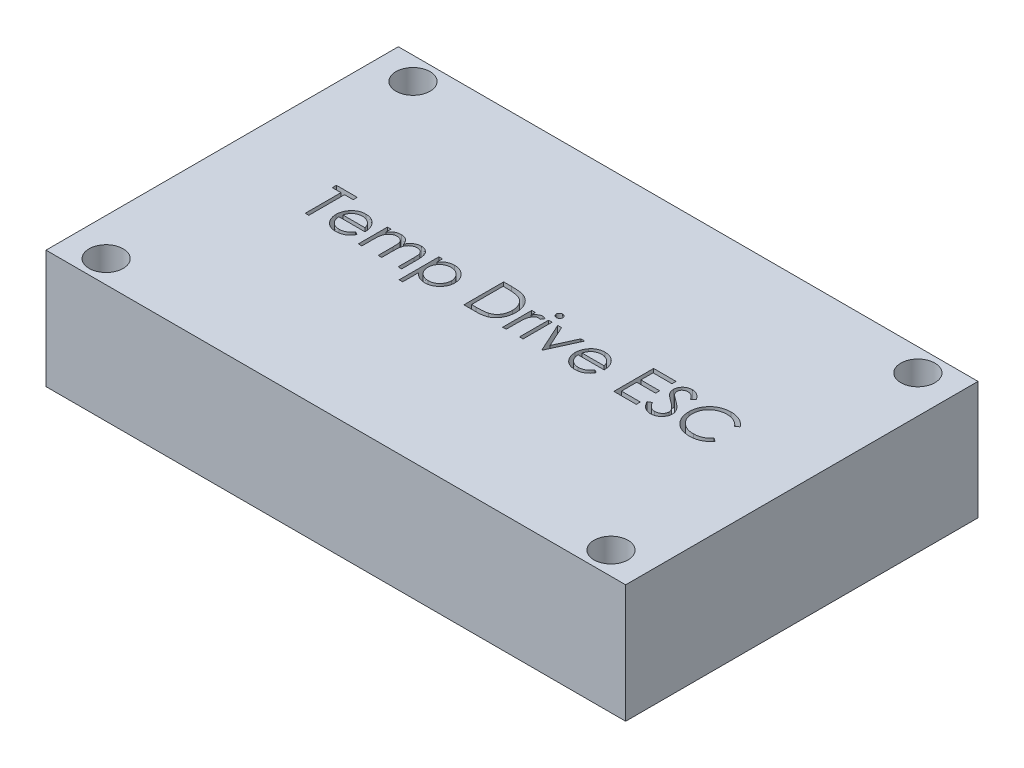
from build123d import *

# Parameters (mm, degrees)
SKETCH1_W           = 51
SKETCH1_H           = 31
SKETCH1_R           = 1.5
BOSS_EXTRUDE1_DEPTH = 10.4
SKETCH2_W           = 0.314102564
SKETCH2_H           = 2.557692308
CUT_EXTRUDE1_DEPTH  = 1.4


with BuildPart() as part:
    # Sketch1 → Boss-Extrude1 (new body)
    with BuildSketch(Plane(origin=(0, 0, 0), x_dir=(1, 0, 0), z_dir=(0, 1, 0))):
        Rectangle(SKETCH1_W, SKETCH1_H)
        with Locations((-22.209677419, 13.5)):
            Circle(SKETCH1_R, mode=Mode.SUBTRACT)
        with Locations((22.209677419, 13.5)):
            Circle(SKETCH1_R, mode=Mode.SUBTRACT)
        with Locations((22.209677419, -13.5)):
            Circle(SKETCH1_R, mode=Mode.SUBTRACT)
        with Locations((-22.209677419, -13.5)):
            Circle(SKETCH1_R, mode=Mode.SUBTRACT)
    extrude(amount=BOSS_EXTRUDE1_DEPTH)

    # Sketch2 → Cut-Extrude1 (cut)
    with BuildSketch(Plane(origin=(0, 10.4, 0), x_dir=(1, 0, 0), z_dir=(0, 1, 0))):
        Polygon((-17.667113502, 1.856715019), (-17.667113502, 2.215689378), (-15.827369912, 2.215689378), (-15.827369912, 1.856715019), (-16.590190425, 1.856715019), (-16.590190425, -1.284310622), (-16.904292989, -1.284310622), (-16.904292989, 1.856715019), align=None)
        with BuildLine():
            Line((-13.279493309, -0.476618314), (-13.000446835, -0.62315277))
            add(Edge.make_bspline(
                [(-13.000446835, -0.62315277), (-13.02268343, -0.662596101), (-13.065947039, -0.739337204), (-13.140347787, -0.844769064), (-13.218339859, -0.93961678), (-13.303443827, -1.021346434), (-13.393113506, -1.092597819), (-13.487846161, -1.154935644), (-13.588134979, -1.208054164), (-13.693984703, -1.252806692), (-13.806284255, -1.287216186), (-13.925305771, -1.311520407), (-14.051277266, -1.326543676), (-14.137623446, -1.328288817), (-14.181837059, -1.329182417)],
                knots=[0, 0, 0, 0, 0.000135759, 0.000264133, 0.000386579, 0.000503597, 0.000617365, 0.000729763, 0.000843304, 0.000957371, 0.001074023, 0.001195027, 0.001321389, 0.001453992, 0.001453992, 0.001453992, 0.001453992], degree=3))
            add(Edge.make_bspline(
                [(-14.181837059, -1.329182417), (-14.230979037, -1.328035242), (-14.326840799, -1.325797435), (-14.466380546, -1.306504971), (-14.597759964, -1.275032612), (-14.720971667, -1.23106707), (-14.83571392, -1.173639746), (-14.942214775, -1.103680264), (-15.041034301, -1.02154801), (-15.12905851, -0.926531566), (-15.208302393, -0.824849609), (-15.278228213, -0.718893724), (-15.336685644, -0.6089305), (-15.384238254, -0.495659976), (-15.422643119, -0.379796082), (-15.449409823, -0.260284615), (-15.464839571, -0.137449031), (-15.467204016, -0.054351695), (-15.468395553, -0.012475686)],
                knots=[0, 0, 0, 0, 0.000147371, 0.000287478, 0.000421649, 0.000552053, 0.000679042, 0.000805636, 0.000933558, 0.00106351, 0.001193382, 0.001319977, 0.001443869, 0.001566405, 0.001688128, 0.001809576, 0.001933238, 0.002058864, 0.002058864, 0.002058864, 0.002058864], degree=3))
            add(Edge.make_bspline(
                [(-15.468395553, -0.012475686), (-15.467336412, 0.026819144), (-15.465237333, 0.104696309), (-15.452006546, 0.219961853), (-15.428558253, 0.331990306), (-15.396381929, 0.440874754), (-15.354830683, 0.546432888), (-15.303998464, 0.648728951), (-15.243806086, 0.747654091), (-15.197333412, 0.810057225), (-15.173924399, 0.84149066)],
                knots=[0, 0, 0, 0, 0.000117891, 0.000233644, 0.000347498, 0.000460856, 0.000573868, 0.000687374, 0.000803169, 0.000920699, 0.000920699, 0.000920699, 0.000920699], degree=3))
            add(Edge.make_bspline(
                [(-15.173924399, 0.84149066), (-15.142216716, 0.87935953), (-15.07980577, 0.95389768), (-14.974249414, 1.051836006), (-14.859949218, 1.133879781), (-14.738337592, 1.201886918), (-14.608001118, 1.253560565), (-14.470691827, 1.292068147), (-14.324846241, 1.313646158), (-14.22514102, 1.316693991), (-14.17412472, 1.31825348)],
                knots=[0, 0, 0, 0, 0.000148071, 0.000291452, 0.00043058, 0.000569298, 0.000708346, 0.00085021, 0.000996268, 0.001149307, 0.001149307, 0.001149307, 0.001149307], degree=3))
            add(Edge.make_bspline(
                [(-14.17412472, 1.31825348), (-14.121677114, 1.316899432), (-14.018786868, 1.314243096), (-13.868754747, 1.289616763), (-13.726794031, 1.250564208), (-13.592961527, 1.195410418), (-13.467243666, 1.124250866), (-13.350457616, 1.036109025), (-13.240606104, 0.933690937), (-13.176697525, 0.854927728), (-13.144176803, 0.814848032)],
                knots=[0, 0, 0, 0, 0.000157241, 0.00030847, 0.000454763, 0.000598116, 0.000741606, 0.000886879, 0.001036172, 0.001190853, 0.001190853, 0.001190853, 0.001190853], degree=3))
            add(Edge.make_bspline(
                [(-13.144176803, 0.814848032), (-13.122049865, 0.78464445), (-13.077943272, 0.724438332), (-13.022696172, 0.626267175), (-12.974738777, 0.52355658), (-12.936405816, 0.414646283), (-12.905366314, 0.300826703), (-12.882909496, 0.181284158), (-12.869739877, 0.056054247), (-12.86715118, -0.029272309), (-12.86583145, -0.072772161)],
                knots=[0, 0, 0, 0, 0.000112234, 0.000223721, 0.000337279, 0.000451932, 0.000569628, 0.000690912, 0.000816421, 0.00094695, 0.00094695, 0.00094695, 0.00094695], degree=3))
            Line((-12.86583145, -0.072772161), (-15.154292989, -0.072772161))
            add(Edge.make_bspline(
                [(-15.154292989, -0.072772161), (-15.152753382, -0.106472625), (-15.149725808, -0.172743229), (-15.135610665, -0.269714012), (-15.113361892, -0.362087354), (-15.082092829, -0.449170396), (-15.044225984, -0.532100523), (-14.997840267, -0.61026256), (-14.942500713, -0.68330049), (-14.880775014, -0.751867628), (-14.812067918, -0.812928389), (-14.739785171, -0.867580165), (-14.662891606, -0.913385762), (-14.581993522, -0.950565652), (-14.497221737, -0.979671968), (-14.408549542, -0.999539789), (-14.316151426, -1.012846895), (-14.253165692, -1.014326561), (-14.22109988, -1.015079853)],
                knots=[0, 0, 0, 0, 0.000101159, 0.000198924, 0.000293472, 0.000385722, 0.000476069, 0.000566611, 0.000657757, 0.000750573, 0.000842919, 0.000933083, 0.001022062, 0.001110842, 0.001199752, 0.001290403, 0.001383113, 0.001479259, 0.001479259, 0.001479259, 0.001479259], degree=3))
            add(Edge.make_bspline(
                [(-14.22109988, -1.015079853), (-14.189748732, -1.014471796), (-14.127542041, -1.013265295), (-14.034901184, -1.001533384), (-13.943761657, -0.982563109), (-13.854500673, -0.956673119), (-13.768929827, -0.925096266), (-13.689684277, -0.886993409), (-13.616804062, -0.844843662), (-13.548687095, -0.796633987), (-13.482616102, -0.7376258), (-13.417073615, -0.663990079), (-13.346796962, -0.576902551), (-13.302807369, -0.511356885), (-13.279493309, -0.476618314)],
                knots=[0, 0, 0, 0, 9.4016e-05, 0.000186545, 0.000279636, 0.000373054, 0.000465125, 0.000552934, 0.000636508, 0.000717442, 0.000802858, 0.000901616, 0.001012865, 0.001138311, 0.001138311, 0.001138311, 0.001138311], degree=3))
        make_face()
        with BuildLine():
            add(Edge.make_bspline(
                [(-13.179934015, 0.241330403), (-13.191430639, 0.282993277), (-13.213557941, 0.363180898), (-13.259794305, 0.474221788), (-13.311865846, 0.572909689), (-13.373487577, 0.658489322), (-13.443306303, 0.734492835), (-13.523951485, 0.80091142), (-13.614387379, 0.860328872), (-13.71414652, 0.910481371), (-13.819788305, 0.95317123), (-13.930394497, 0.981796345), (-14.043252284, 1.001405888), (-14.119586571, 1.003231996), (-14.157998918, 1.004150916)],
                knots=[0, 0, 0, 0, 0.000129543, 0.000249328, 0.000360065, 0.000463575, 0.000564789, 0.000668832, 0.000776175, 0.000888744, 0.001003316, 0.001117263, 0.001230914, 0.001346035, 0.001346035, 0.001346035, 0.001346035], degree=3))
            add(Edge.make_bspline(
                [(-14.157998918, 1.004150916), (-14.189348357, 1.003539245), (-14.251319606, 1.002330099), (-14.342620674, 0.990859969), (-14.430300373, 0.971900125), (-14.515005661, 0.945935168), (-14.595626529, 0.911326565), (-14.673821297, 0.870743339), (-14.747601693, 0.821201755), (-14.793742989, 0.7834429), (-14.817053406, 0.764367262)],
                knots=[0, 0, 0, 0, 9.4016e-05, 0.000185849, 0.000275511, 0.000362884, 0.000451173, 0.00053836, 0.000626838, 0.000717174, 0.000717174, 0.000717174, 0.000717174], degree=3))
            add(Edge.make_bspline(
                [(-14.817053406, 0.764367262), (-14.833746687, 0.749272947), (-14.867529822, 0.718725731), (-14.912670343, 0.666096524), (-14.955890816, 0.609344962), (-14.995224469, 0.546299837), (-15.031302055, 0.477679058), (-15.065062032, 0.404061423), (-15.095448444, 0.324888293), (-15.112544554, 0.269715854), (-15.121340265, 0.241330403)],
                knots=[0, 0, 0, 0, 6.7454e-05, 0.00013651, 0.000207604, 0.000281328, 0.000359112, 0.000440057, 0.000524171, 0.000613305, 0.000613305, 0.000613305, 0.000613305], degree=3))
            Line((-15.121340265, 0.241330403), (-13.179934015, 0.241330403))
        make_face(mode=Mode.SUBTRACT)
        with BuildLine():
            Line((-12.237626322, 1.273381686), (-11.923523758, 1.273381686))
            Line((-11.923523758, 1.273381686), (-11.923523758, 0.828870468))
            add(Edge.make_bspline(
                [(-11.923523758, 0.828870468), (-11.895239808, 0.867758069), (-11.841045049, 0.942270442), (-11.752179396, 1.040460727), (-11.663403284, 1.123788881), (-11.599469902, 1.167531753), (-11.56875613, 1.188545948)],
                knots=[0, 0, 0, 0, 0.000144152, 0.000276209, 0.000396804, 0.000508302, 0.000508302, 0.000508302, 0.000508302], degree=3))
            add(Edge.make_bspline(
                [(-11.56875613, 1.188545948), (-11.526891468, 1.208551314), (-11.443893568, 1.248212527), (-11.312474343, 1.288446086), (-11.177999674, 1.313171187), (-11.08719146, 1.316552561), (-11.04151254, 1.31825348)],
                knots=[0, 0, 0, 0, 0.000139031, 0.000275633, 0.000410962, 0.000547939, 0.000547939, 0.000547939, 0.000547939], degree=3))
            add(Edge.make_bspline(
                [(-11.04151254, 1.31825348), (-11.010619544, 1.31720819), (-10.949483965, 1.315139615), (-10.858899874, 1.30167958), (-10.771041263, 1.278413407), (-10.686427233, 1.246006083), (-10.606706554, 1.206759396), (-10.533617356, 1.160709688), (-10.467993148, 1.109012613), (-10.409867097, 1.04933368), (-10.357598071, 0.979997081), (-10.309519225, 0.899132833), (-10.265094012, 0.804925172), (-10.240472704, 0.736558631), (-10.227510136, 0.700565179)],
                knots=[0, 0, 0, 0, 9.2678e-05, 0.000183405, 0.000274048, 0.000364807, 0.000454797, 0.00054019, 0.000623517, 0.000704829, 0.000789387, 0.000883415, 0.000986597, 0.001101318, 0.001101318, 0.001101318, 0.001101318], degree=3))
            add(Edge.make_bspline(
                [(-10.227510136, 0.700565179), (-10.213798885, 0.725289598), (-10.186817068, 0.773943783), (-10.141511431, 0.842802046), (-10.094043634, 0.907208837), (-10.044009141, 0.967215262), (-9.991584554, 1.022524992), (-9.936523154, 1.073320894), (-9.879138373, 1.119821108), (-9.799346133, 1.174144267), (-9.695533525, 1.231845448), (-9.564645411, 1.281873892), (-9.428495239, 1.312790021), (-9.336077541, 1.316420294), (-9.289409175, 1.31825348)],
                knots=[0, 0, 0, 0, 8.4789e-05, 0.000166854, 0.000247064, 0.000324714, 0.000401089, 0.000475513, 0.000549314, 0.000622436, 0.0007649, 0.000904487, 0.001041601, 0.001181469, 0.001181469, 0.001181469, 0.001181469], degree=3))
            add(Edge.make_bspline(
                [(-9.289409175, 1.31825348), (-9.246527712, 1.31663626), (-9.162604526, 1.313471201), (-9.04042726, 1.288617728), (-8.926485455, 1.245940081), (-8.821008379, 1.187706444), (-8.725848565, 1.114527261), (-8.643132256, 1.027458423), (-8.573361893, 0.9271158), (-8.527783253, 0.832723812), (-8.496867989, 0.749388479), (-8.477806754, 0.678382188), (-8.460967059, 0.600230635), (-8.446985814, 0.514840373), (-8.436767262, 0.421909765), (-8.429196546, 0.321590889), (-8.424072473, 0.213805777), (-8.423710401, 0.139440277), (-8.423523758, 0.101106045)],
                knots=[0, 0, 0, 0, 0.000128581, 0.000251645, 0.00037211, 0.000492305, 0.000611786, 0.000730807, 0.000851198, 0.000976936, 0.001044145, 0.001117629, 0.001197252, 0.00128393, 0.001377074, 0.001477631, 0.001585715, 0.001700707, 0.001700707, 0.001700707, 0.001700707], degree=3))
            Line((-8.423523758, 0.101106045), (-8.423523758, -1.284310622))
            Line((-8.423523758, -1.284310622), (-8.737626322, -1.284310622))
            Line((-8.737626322, -1.284310622), (-8.737626322, 0.102508288))
            add(Edge.make_bspline(
                [(-8.737626322, 0.102508288), (-8.737704205, 0.135228862), (-8.737853884, 0.198112829), (-8.740547516, 0.28836528), (-8.74562283, 0.370633637), (-8.751557469, 0.444805725), (-8.759801278, 0.511054514), (-8.77044721, 0.569246933), (-8.78172489, 0.619840744), (-8.800460881, 0.675926792), (-8.830408773, 0.737797002), (-8.876026253, 0.804520578), (-8.933496359, 0.862601378), (-8.999856515, 0.913019695), (-9.07540496, 0.954013336), (-9.158669683, 0.983289346), (-9.249133735, 1.001412224), (-9.311756523, 1.00321824), (-9.344096675, 1.004150916)],
                knots=[0, 0, 0, 0, 9.816e-05, 0.000188648, 0.000270826, 0.000345412, 0.000411852, 0.000470988, 0.000522857, 0.0005672, 0.000648106, 0.000728233, 0.000808554, 0.000892128, 0.000977461, 0.001065278, 0.001156029, 0.001252946, 0.001252946, 0.001252946, 0.001252946], degree=3))
            add(Edge.make_bspline(
                [(-9.344096675, 1.004150916), (-9.383766629, 1.002734759), (-9.46216954, 0.999935894), (-9.576615027, 0.971362021), (-9.686586043, 0.92828177), (-9.788801176, 0.865849313), (-9.882828967, 0.791040949), (-9.963728544, 0.702091353), (-10.03056073, 0.601461426), (-10.075814706, 0.508314724), (-10.104404007, 0.42464528), (-10.123280923, 0.351547908), (-10.137964315, 0.26846634), (-10.151734844, 0.175958849), (-10.160722572, 0.073388669), (-10.168890944, -0.038769732), (-10.172711807, -0.160853691), (-10.173246266, -0.24548038), (-10.173523758, -0.289418795)],
                knots=[0, 0, 0, 0, 0.000118788, 0.00023477, 0.000351815, 0.000471937, 0.000592603, 0.000711217, 0.000831002, 0.000953929, 0.001020668, 0.001096002, 0.00118016, 0.001273662, 0.001376495, 0.001488939, 0.001611007, 0.001742825, 0.001742825, 0.001742825, 0.001742825], degree=3))
            Line((-10.173523758, -0.289418795), (-10.173523758, -1.284310622))
            Line((-10.173523758, -1.284310622), (-10.487626322, -1.284310622))
            Line((-10.487626322, -1.284310622), (-10.487626322, 0.016270307))
            add(Edge.make_bspline(
                [(-10.487626322, 0.016270307), (-10.487705753, 0.052963626), (-10.48785857, 0.123557883), (-10.490534888, 0.224791559), (-10.495621509, 0.316872639), (-10.501502058, 0.399694103), (-10.509962236, 0.473105431), (-10.519571998, 0.537500189), (-10.530920609, 0.59271694), (-10.549710494, 0.653280325), (-10.578424962, 0.720001248), (-10.624613224, 0.791142269), (-10.682220804, 0.853410367), (-10.74979168, 0.906569115), (-10.825797362, 0.950510597), (-10.909780763, 0.982170348), (-11.000985676, 1.000594638), (-11.063863382, 1.002943135), (-11.09620004, 1.004150916)],
                knots=[0, 0, 0, 0, 0.000110078, 0.00021178, 0.000303758, 0.00038673, 0.000460827, 0.00052538, 0.000582037, 0.000629718, 0.00071543, 0.000799052, 0.000882908, 0.000968755, 0.001056067, 0.001145266, 0.001236843, 0.001333803, 0.001333803, 0.001333803, 0.001333803], degree=3))
            add(Edge.make_bspline(
                [(-11.09620004, 1.004150916), (-11.134216252, 1.002620456), (-11.209981211, 0.999570304), (-11.321283181, 0.97211603), (-11.428768864, 0.929111955), (-11.530723563, 0.869452136), (-11.624397711, 0.795553058), (-11.706405979, 0.708638162), (-11.775348504, 0.609789128), (-11.821080319, 0.517624612), (-11.850578793, 0.436051337), (-11.870174128, 0.366700389), (-11.887013754, 0.289700141), (-11.899527775, 0.20481303), (-11.911608191, 0.112591936), (-11.9174385, 0.012577446), (-11.923110062, -0.095144642), (-11.923382477, -0.169517187), (-11.923523758, -0.208088667)],
                knots=[0, 0, 0, 0, 0.000113893, 0.000226985, 0.000341817, 0.000460265, 0.000580056, 0.000698595, 0.000817435, 0.000940348, 0.001005999, 0.001077458, 0.001156396, 0.001242271, 0.001334801, 0.001435306, 0.00154269, 0.001658383, 0.001658383, 0.001658383, 0.001658383], degree=3))
            Line((-11.923523758, -0.208088667), (-11.923523758, -1.284310622))
            Line((-11.923523758, -1.284310622), (-12.237626322, -1.284310622))
            Line((-12.237626322, -1.284310622), (-12.237626322, 1.273381686))
        make_face()
        with BuildLine():
            Line((-7.70557504, 1.273381686), (-7.391472476, 1.273381686))
            Line((-7.391472476, 1.273381686), (-7.391472476, 0.800124474))
            add(Edge.make_bspline(
                [(-7.391472476, 0.800124474), (-7.358114992, 0.843062208), (-7.293291397, 0.926503101), (-7.181566492, 1.034493229), (-7.063639684, 1.125568533), (-6.936476271, 1.196951066), (-6.802052581, 1.250771878), (-6.660920264, 1.290551328), (-6.511881499, 1.313992802), (-6.409985046, 1.316814464), (-6.35801895, 1.31825348)],
                knots=[0, 0, 0, 0, 0.00016294, 0.00031664, 0.000464722, 0.000608822, 0.000752559, 0.000898176, 0.001047911, 0.001203751, 0.001203751, 0.001203751, 0.001203751], degree=3))
            add(Edge.make_bspline(
                [(-6.35801895, 1.31825348), (-6.312627347, 1.316940302), (-6.222908459, 1.314344734), (-6.09084523, 1.29677168), (-5.963669846, 1.266653987), (-5.842101792, 1.223253072), (-5.724838727, 1.169597602), (-5.613616627, 1.101880567), (-5.506703072, 1.023474376), (-5.406786883, 0.933242225), (-5.314465515, 0.835613959), (-5.234619334, 0.730591654), (-5.16574743, 0.621629068), (-5.110077133, 0.507036976), (-5.066468786, 0.387717746), (-5.035454108, 0.263189305), (-5.016996465, 0.133913365), (-5.014520013, 0.046010644), (-5.013267348, 0.00154675)],
                knots=[0, 0, 0, 0, 0.000136164, 0.000269135, 0.000398888, 0.000527501, 0.000655799, 0.000785059, 0.000917435, 0.001052984, 0.001188402, 0.001319939, 0.001448139, 0.001574506, 0.001701376, 0.001828571, 0.001958859, 0.002092222, 0.002092222, 0.002092222, 0.002092222], degree=3))
            add(Edge.make_bspline(
                [(-5.013267348, 0.00154675), (-5.014492833, -0.043855559), (-5.016909668, -0.133395463), (-5.035654674, -0.264882561), (-5.065611548, -0.391369934), (-5.108669731, -0.512647198), (-5.164311219, -0.628630849), (-5.23201578, -0.739237245), (-5.311902247, -0.844430949), (-5.403203375, -0.942783849), (-5.502256311, -1.033383162), (-5.6081338, -1.112621231), (-5.719192726, -1.179162606), (-5.834864893, -1.234745566), (-5.956140531, -1.27663775), (-6.082453809, -1.306855551), (-6.213735955, -1.325490046), (-6.303037107, -1.327942189), (-6.348203245, -1.329182417)],
                knots=[0, 0, 0, 0, 0.000136164, 0.000268535, 0.000397606, 0.000525558, 0.00065382, 0.000782843, 0.000913955, 0.001049409, 0.001184907, 0.001316158, 0.001445417, 0.001572744, 0.001700463, 0.001829535, 0.001961906, 0.002097369, 0.002097369, 0.002097369, 0.002097369], degree=3))
            add(Edge.make_bspline(
                [(-6.348203245, -1.329182417), (-6.399030817, -1.327887609), (-6.499430173, -1.325329984), (-6.646227844, -1.299410574), (-6.787504696, -1.260673639), (-6.92169552, -1.203974645), (-7.049863333, -1.131719129), (-7.171283139, -1.043608923), (-7.286599892, -0.939828299), (-7.356008649, -0.861096482), (-7.391472476, -0.820869116)],
                knots=[0, 0, 0, 0, 0.000152339, 0.000300914, 0.000445856, 0.000591043, 0.000736709, 0.000886352, 0.001040245, 0.001201023, 0.001201023, 0.001201023, 0.001201023], degree=3))
            Line((-7.391472476, -0.820869116), (-7.391472476, -2.226618314))
            Line((-7.391472476, -2.226618314), (-7.70557504, -2.226618314))
            Line((-7.70557504, -2.226618314), (-7.70557504, 1.273381686))
        make_face()
        with BuildLine():
            add(Edge.make_bspline(
                [(-6.360823438, 1.004150916), (-6.396403, 1.003510658), (-6.466449988, 1.002250155), (-6.569122207, 0.987276206), (-6.668017635, 0.965538465), (-6.762139586, 0.932626564), (-6.852390202, 0.892227751), (-6.938074367, 0.84174574), (-7.019131935, 0.782093734), (-7.095358965, 0.71441439), (-7.164222259, 0.639839702), (-7.225185187, 0.560251893), (-7.276392492, 0.475751753), (-7.318894512, 0.387126391), (-7.351237795, 0.293681106), (-7.374193514, 0.195948093), (-7.388623867, 0.093820381), (-7.390512805, 0.024264374), (-7.391472476, -0.011073443)],
                knots=[0, 0, 0, 0, 0.000106654, 0.000209973, 0.000310662, 0.000409994, 0.000508521, 0.000606883, 0.00070771, 0.000810012, 0.000912217, 0.001011779, 0.001110258, 0.001208104, 0.001306111, 0.001406276, 0.001508901, 0.001614884, 0.001614884, 0.001614884, 0.001614884], degree=3))
            add(Edge.make_bspline(
                [(-7.391472476, -0.011073443), (-7.38988162, -0.057461555), (-7.386764998, -0.148339796), (-7.36142763, -0.281123918), (-7.320192366, -0.406775574), (-7.261663652, -0.524236611), (-7.187716078, -0.632219446), (-7.098617922, -0.728910052), (-6.995175371, -0.813700643), (-6.879108179, -0.885121897), (-6.754686048, -0.943109964), (-6.624900136, -0.984624174), (-6.491535255, -1.010196402), (-6.401366936, -1.013443221), (-6.355915585, -1.015079853)],
                knots=[0, 0, 0, 0, 0.000139077, 0.000272463, 0.00040394, 0.000534691, 0.000664794, 0.000795295, 0.000927798, 0.001064768, 0.001203104, 0.001338581, 0.001472656, 0.001608934, 0.001608934, 0.001608934, 0.001608934], degree=3))
            add(Edge.make_bspline(
                [(-6.355915585, -1.015079853), (-6.311379817, -1.013523476), (-6.222984324, -1.010434348), (-6.092826203, -0.98369616), (-5.966335564, -0.942851136), (-5.846155392, -0.883291579), (-5.733331904, -0.810301521), (-5.63145035, -0.722741488), (-5.542443437, -0.621251545), (-5.466579082, -0.508243042), (-5.405447596, -0.387067658), (-5.359517357, -0.26168627), (-5.333008783, -0.132540847), (-5.329251995, -0.045543134), (-5.327369912, -0.001958859)],
                knots=[0, 0, 0, 0, 0.000133479, 0.000264931, 0.000397073, 0.000531279, 0.000666044, 0.000799279, 0.000932907, 0.001069805, 0.001206515, 0.001339137, 0.001469351, 0.001600078, 0.001600078, 0.001600078, 0.001600078], degree=3))
            add(Edge.make_bspline(
                [(-5.327369912, -0.001958859), (-5.328824646, 0.04189613), (-5.33172278, 0.129264433), (-5.360269817, 0.258027336), (-5.403169795, 0.383915313), (-5.465728847, 0.503435862), (-5.539930116, 0.616209945), (-5.629677113, 0.715763824), (-5.73029331, 0.802934497), (-5.842982474, 0.874949907), (-5.963922899, 0.932235401), (-6.091237815, 0.97411904), (-6.224281418, 0.99929279), (-6.314909072, 1.002517296), (-6.360823438, 1.004150916)],
                knots=[0, 0, 0, 0, 0.000131379, 0.000261735, 0.000393889, 0.000529349, 0.000665274, 0.000797853, 0.0009301, 0.001063514, 0.001197743, 0.001330552, 0.001464627, 0.001602305, 0.001602305, 0.001602305, 0.001602305], degree=3))
        make_face(mode=Mode.SUBTRACT)
        with BuildLine():
            Line((-2.949164784, -1.284310622), (-2.949164784, 2.215689378))
            Line((-2.949164784, 2.215689378), (-2.242434015, 2.215689378))
            add(Edge.make_bspline(
                [(-2.242434015, 2.215689378), (-2.180965026, 2.215246808), (-2.062207261, 2.214391765), (-1.890594814, 2.208970374), (-1.731811051, 2.199379908), (-1.586378192, 2.185410382), (-1.45389698, 2.168257348), (-1.334738372, 2.146756944), (-1.228286229, 2.121368773), (-1.162816788, 2.099723323), (-1.131857091, 2.089487455)],
                knots=[0, 0, 0, 0, 0.000184407, 0.000356273, 0.000515031, 0.000661537, 0.000794508, 0.000915664, 0.001024665, 0.001122454, 0.001122454, 0.001122454, 0.001122454], degree=3))
            add(Edge.make_bspline(
                [(-1.131857091, 2.089487455), (-1.091362352, 2.074056749), (-1.01129116, 2.043545255), (-0.897284037, 1.985988954), (-0.789958674, 1.920775852), (-0.688739529, 1.847819989), (-0.595938703, 1.765055641), (-0.507930806, 1.675998555), (-0.428316082, 1.577410215), (-0.355407786, 1.471335227), (-0.289672127, 1.359023175), (-0.232532969, 1.240688066), (-0.185078976, 1.116930858), (-0.145685749, 0.98809571), (-0.114639292, 0.853899332), (-0.09345736, 0.714185466), (-0.07948637, 0.569506277), (-0.078082319, 0.471331813), (-0.077369912, 0.421518705)],
                knots=[0, 0, 0, 0, 0.000129935, 0.000256923, 0.000382457, 0.000506429, 0.000630624, 0.000755071, 0.000881654, 0.001010204, 0.001140916, 0.00127168, 0.001403968, 0.001538146, 0.001675568, 0.001816774, 0.001961818, 0.002111216, 0.002111216, 0.002111216, 0.002111216], degree=3))
            add(Edge.make_bspline(
                [(-0.077369912, 0.421518705), (-0.077998879, 0.378257466), (-0.079238326, 0.293006677), (-0.090367641, 0.167365782), (-0.106543961, 0.04545221), (-0.131588159, -0.07215349), (-0.161990673, -0.186481708), (-0.200954824, -0.296313952), (-0.24559032, -0.402657761), (-0.297640199, -0.504075237), (-0.354781584, -0.600158609), (-0.416103327, -0.690734138), (-0.481540022, -0.774509359), (-0.551715655, -0.851737971), (-0.625723372, -0.92230355), (-0.704047702, -0.986795565), (-0.786890753, -1.04395212), (-0.873881476, -1.096019228), (-0.967557605, -1.141439584), (-1.069693471, -1.179869594), (-1.180724649, -1.211716209), (-1.300378606, -1.238287105), (-1.428862084, -1.259364407), (-1.56630105, -1.2734908), (-1.712484339, -1.283043733), (-1.812863605, -1.283880126), (-1.864529367, -1.284310622)],
                knots=[0, 0, 0, 0, 0.000129755, 0.000255696, 0.000378151, 0.000498469, 0.000616165, 0.000732801, 0.000847787, 0.000961923, 0.00107447, 0.001182981, 0.001289856, 0.001393094, 0.001495748, 0.001596383, 0.00169713, 0.001797413, 0.001900265, 0.002008995, 0.002124372, 0.002246504, 0.002376522, 0.002514729, 0.002660846, 0.00281582, 0.00281582, 0.00281582, 0.00281582], degree=3))
            Line((-1.864529367, -1.284310622), (-2.949164784, -1.284310622))
        make_face()
        with BuildLine():
            Line((-2.63506222, -0.925336263), (-2.233319431, -0.925336263))
            add(Edge.make_bspline(
                [(-2.233319431, -0.925336263), (-2.17559106, -0.925088167), (-2.064558262, -0.924610987), (-1.904900265, -0.920423783), (-1.759020868, -0.913581846), (-1.626899359, -0.904006768), (-1.508610335, -0.891338153), (-1.403906585, -0.87721325), (-1.313131326, -0.859615799), (-1.258201889, -0.84366484), (-1.23281863, -0.836293795)],
                knots=[0, 0, 0, 0, 0.000173183, 0.000333094, 0.000479096, 0.000611272, 0.000730431, 0.000835931, 0.000928194, 0.001007458, 0.001007458, 0.001007458, 0.001007458], degree=3))
            add(Edge.make_bspline(
                [(-1.23281863, -0.836293795), (-1.200870268, -0.825042237), (-1.13773663, -0.802807864), (-1.046855544, -0.762250203), (-0.96209854, -0.714208133), (-0.881988514, -0.660805859), (-0.807661859, -0.600159857), (-0.738237743, -0.533588868), (-0.673855941, -0.460754093), (-0.615181633, -0.381745931), (-0.562673329, -0.297056136), (-0.5172021, -0.207517302), (-0.477350568, -0.114110492), (-0.446071976, -0.015401333), (-0.421556392, 0.087727725), (-0.404191704, 0.195283939), (-0.393376979, 0.30724722), (-0.392115531, 0.383399345), (-0.391472476, 0.422219827)],
                knots=[0, 0, 0, 0, 0.000101593, 0.000200759, 0.000298073, 0.000393552, 0.000489254, 0.000585454, 0.000681817, 0.000780535, 0.000880346, 0.000980374, 0.001081551, 0.001184655, 0.001290601, 0.001399295, 0.001511268, 0.001627707, 0.001627707, 0.001627707, 0.001627707], degree=3))
            add(Edge.make_bspline(
                [(-0.391472476, 0.422219827), (-0.391985763, 0.463153307), (-0.392994121, 0.543567491), (-0.405668431, 0.661558187), (-0.424189987, 0.775038837), (-0.450973673, 0.884017032), (-0.485104552, 0.988705385), (-0.527699194, 1.088524895), (-0.576365813, 1.184529764), (-0.63426915, 1.274504129), (-0.697684743, 1.359597239), (-0.768062622, 1.437552154), (-0.844284661, 1.508546454), (-0.92551951, 1.573685767), (-1.01405661, 1.630349443), (-1.1078103, 1.681036124), (-1.208155972, 1.724052015), (-1.277968667, 1.746930878), (-1.313447636, 1.758557968)],
                knots=[0, 0, 0, 0, 0.000122746, 0.000241136, 0.000355593, 0.000467485, 0.000577457, 0.000685538, 0.00079278, 0.000899951, 0.001006101, 0.00111085, 0.001214524, 0.001318328, 0.001422759, 0.001529413, 0.00163777, 0.001749741, 0.001749741, 0.001749741, 0.001749741], degree=3))
            add(Edge.make_bspline(
                [(-1.313447636, 1.758557968), (-1.342798783, 1.766674395), (-1.405207373, 1.783932148), (-1.507046837, 1.802757521), (-1.621661986, 1.81936202), (-1.749561688, 1.833420059), (-1.890600147, 1.84350738), (-2.044885835, 1.851078695), (-2.212485439, 1.856185327), (-2.328667973, 1.856534035), (-2.38896847, 1.856715019)],
                knots=[0, 0, 0, 0, 9.1321e-05, 0.000194173, 0.000310382, 0.000438754, 0.000580072, 0.000734511, 0.000902151, 0.001083046, 0.001083046, 0.001083046, 0.001083046], degree=3))
            Line((-2.38896847, 1.856715019), (-2.63506222, 1.856715019))
            Line((-2.63506222, 1.856715019), (-2.63506222, -0.925336263))
        make_face(mode=Mode.SUBTRACT)
        with BuildLine():
            Line((0.461091627, 1.273381686), (0.775194191, 1.273381686))
            Line((0.775194191, 1.273381686), (0.775194191, 0.896879282))
            add(Edge.make_bspline(
                [(0.775194191, 0.896879282), (0.798382949, 0.93193511), (0.84273127, 0.998979109), (0.9164442, 1.08764841), (0.991947531, 1.161063457), (1.069602718, 1.219566976), (1.149980818, 1.263380095), (1.23131777, 1.29547313), (1.31489324, 1.314450445), (1.371055164, 1.316984104), (1.399192588, 1.31825348)],
                knots=[0, 0, 0, 0, 0.000126023, 0.000241017, 0.000345147, 0.000441342, 0.00053171, 0.000618946, 0.000702978, 0.000787349, 0.000787349, 0.000787349, 0.000787349], degree=3))
            add(Edge.make_bspline(
                [(1.399192588, 1.31825348), (1.421018915, 1.317062954), (1.465928, 1.314613368), (1.53391059, 1.297402543), (1.603954041, 1.269924521), (1.649096429, 1.244084298), (1.672630088, 1.230613256)],
                knots=[0, 0, 0, 0, 6.5445e-05, 0.000134658, 0.00020926, 0.000290509, 0.000290509, 0.000290509, 0.000290509], degree=3))
            Line((1.672630088, 1.230613256), (1.500154127, 0.958578))
            add(Edge.make_bspline(
                [(1.500154127, 0.958578), (1.485045105, 0.965318266), (1.456365291, 0.978112581), (1.414410725, 0.993254591), (1.375729388, 1.002170507), (1.351085829, 1.003521225), (1.339597235, 1.004150916)],
                knots=[0, 0, 0, 0, 4.9621e-05, 9.4191e-05, 0.00013366, 0.000168129, 0.000168129, 0.000168129, 0.000168129], degree=3))
            add(Edge.make_bspline(
                [(1.339597235, 1.004150916), (1.314391502, 1.002470879), (1.262979112, 0.99904409), (1.187494613, 0.972105282), (1.114247407, 0.928580042), (1.056075745, 0.88030893), (1.011033492, 0.833761133), (0.978893266, 0.79311273), (0.949410519, 0.747534098), (0.921240299, 0.697804415), (0.895574005, 0.643074569), (0.871619336, 0.583891355), (0.849960473, 0.520186226), (0.837610228, 0.475803706), (0.831283934, 0.453069186)],
                knots=[0, 0, 0, 0, 7.549e-05, 0.000153978, 0.000237553, 0.000330197, 0.000379784, 0.000431685, 0.000485357, 0.000542493, 0.000603021, 0.000666557, 0.00073396, 0.000804745, 0.000804745, 0.000804745, 0.000804745], degree=3))
            add(Edge.make_bspline(
                [(0.831283934, 0.453069186), (0.826551541, 0.432792012), (0.816069649, 0.387879613), (0.805878111, 0.312531089), (0.795808593, 0.22350743), (0.788711975, 0.120560837), (0.782133933, 0.003948393), (0.778423851, -0.126507553), (0.77532071, -0.270940904), (0.775237643, -0.371915257), (0.775194191, -0.424735302)],
                knots=[0, 0, 0, 0, 6.2435e-05, 0.000138289, 0.000227871, 0.000331224, 0.000447781, 0.000578258, 0.000722716, 0.000881171, 0.000881171, 0.000881171, 0.000881171], degree=3))
            Line((0.775194191, -0.424735302), (0.775194191, -1.284310622))
            Line((0.775194191, -1.284310622), (0.461091627, -1.284310622))
            Line((0.461091627, -1.284310622), (0.461091627, 1.273381686))
        make_face()
        with BuildLine():
            add(Edge.make_bspline(
                [(2.097509896, 2.350304762), (2.117001212, 2.34940061), (2.155168951, 2.347630106), (2.210362219, 2.332468629), (2.260619231, 2.306768944), (2.305196964, 2.272289263), (2.343448851, 2.231739819), (2.370229561, 2.184478851), (2.387441957, 2.133420212), (2.389520512, 2.097805123), (2.390578806, 2.07967175)],
                knots=[0, 0, 0, 0, 5.84e-05, 0.000114358, 0.000170171, 0.000226684, 0.000282761, 0.000336156, 0.000388483, 0.00044276, 0.00044276, 0.00044276, 0.00044276], degree=3))
            add(Edge.make_bspline(
                [(2.390578806, 2.07967175), (2.389496646, 2.062009096), (2.387357344, 2.027092121), (2.370242856, 1.976918649), (2.343220618, 1.930314366), (2.305221493, 1.889843656), (2.260612732, 1.855383036), (2.210363946, 1.829678297), (2.155168497, 1.814518159), (2.117001058, 1.812747471), (2.097509896, 1.811843224)],
                knots=[0, 0, 0, 0, 5.2882e-05, 0.000104542, 0.000157332, 0.000213408, 0.000269922, 0.000325735, 0.000381693, 0.000440092, 0.000440092, 0.000440092, 0.000440092], degree=3))
            add(Edge.make_bspline(
                [(2.097509896, 1.811843224), (2.078241621, 1.812712944), (2.04073844, 1.814405741), (1.986371598, 1.829975759), (1.936543109, 1.855391832), (1.891878436, 1.889618017), (1.854648243, 1.930562914), (1.827549917, 1.976890208), (1.810474956, 2.027099363), (1.808330327, 2.062011529), (1.807245473, 2.07967175)],
                knots=[0, 0, 0, 0, 5.7701e-05, 0.000112308, 0.000168121, 0.000224634, 0.000280239, 0.000333029, 0.000384689, 0.000437571, 0.000437571, 0.000437571, 0.000437571], degree=3))
            add(Edge.make_bspline(
                [(1.807245473, 2.07967175), (1.808306559, 2.097802599), (1.8103906, 2.133412732), (1.827562716, 2.184507765), (1.854422524, 2.231489267), (1.891903088, 2.272514766), (1.936536548, 2.306760201), (1.986373293, 2.332171182), (2.040737993, 2.347742522), (2.078241469, 2.349435136), (2.097509896, 2.350304762)],
                knots=[0, 0, 0, 0, 5.4277e-05, 0.000106603, 0.000159999, 0.000215605, 0.000272118, 0.000327931, 0.000382538, 0.000440239, 0.000440239, 0.000440239, 0.000440239], degree=3))
        make_face()
        with Locations((2.098912139, -0.005464468)):
            Rectangle(SKETCH2_W, SKETCH2_H)
        Polygon((2.749553165, 1.273381686), (3.089597235, 1.273381686), (3.938655729, -0.588797802), (4.787714223, 1.273381686), (5.127758293, 1.273381686), (3.961091627, -1.284310622), (3.916219832, -1.284310622), align=None)
        with BuildLine():
            Line((7.765378485, -0.476618314), (8.04442496, -0.62315277))
            add(Edge.make_bspline(
                [(8.04442496, -0.62315277), (8.022188365, -0.662596101), (7.978924756, -0.739337204), (7.904524008, -0.844769064), (7.826531936, -0.93961678), (7.741427968, -1.021346434), (7.651758289, -1.092597819), (7.557025634, -1.154935644), (7.456736816, -1.208054164), (7.350887091, -1.252806692), (7.23858754, -1.287216186), (7.119566024, -1.311520407), (6.993594528, -1.326543676), (6.907248349, -1.328288817), (6.863034735, -1.329182417)],
                knots=[0, 0, 0, 0, 0.000135759, 0.000264133, 0.000386579, 0.000503597, 0.000617365, 0.000729763, 0.000843304, 0.000957371, 0.001074023, 0.001195027, 0.001321389, 0.001453992, 0.001453992, 0.001453992, 0.001453992], degree=3))
            add(Edge.make_bspline(
                [(6.863034735, -1.329182417), (6.813892758, -1.328035242), (6.718030996, -1.325797435), (6.578491249, -1.306504971), (6.447111831, -1.275032612), (6.323900127, -1.23106707), (6.209157875, -1.173639746), (6.10265702, -1.103680264), (6.003837494, -1.02154801), (5.915813285, -0.926531566), (5.836569402, -0.824849609), (5.766643582, -0.718893724), (5.708186151, -0.6089305), (5.660633541, -0.495659976), (5.622228676, -0.379796082), (5.595461972, -0.260284615), (5.580032224, -0.137449031), (5.577667779, -0.054351695), (5.576476242, -0.012475686)],
                knots=[0, 0, 0, 0, 0.000147371, 0.000287478, 0.000421649, 0.000552053, 0.000679042, 0.000805636, 0.000933558, 0.00106351, 0.001193382, 0.001319977, 0.001443869, 0.001566405, 0.001688128, 0.001809576, 0.001933238, 0.002058864, 0.002058864, 0.002058864, 0.002058864], degree=3))
            add(Edge.make_bspline(
                [(5.576476242, -0.012475686), (5.577535383, 0.026819144), (5.579634461, 0.104696309), (5.592865249, 0.219961853), (5.616313542, 0.331990306), (5.648489866, 0.440874754), (5.690041112, 0.546432888), (5.740873331, 0.648728951), (5.801065709, 0.747654091), (5.847538383, 0.810057225), (5.870947396, 0.84149066)],
                knots=[0, 0, 0, 0, 0.000117891, 0.000233644, 0.000347498, 0.000460856, 0.000573868, 0.000687374, 0.000803169, 0.000920699, 0.000920699, 0.000920699, 0.000920699], degree=3))
            add(Edge.make_bspline(
                [(5.870947396, 0.84149066), (5.902655079, 0.87935953), (5.965066025, 0.95389768), (6.07062238, 1.051836006), (6.184922577, 1.133879781), (6.306534203, 1.201886918), (6.436870677, 1.253560565), (6.574179968, 1.292068147), (6.720025554, 1.313646158), (6.819730775, 1.316693991), (6.870747075, 1.31825348)],
                knots=[0, 0, 0, 0, 0.000148071, 0.000291452, 0.00043058, 0.000569298, 0.000708346, 0.00085021, 0.000996268, 0.001149307, 0.001149307, 0.001149307, 0.001149307], degree=3))
            add(Edge.make_bspline(
                [(6.870747075, 1.31825348), (6.923194681, 1.316899432), (7.026084926, 1.314243096), (7.176117048, 1.289616763), (7.318077764, 1.250564208), (7.451910268, 1.195410418), (7.577628129, 1.124250866), (7.694414179, 1.036109025), (7.804265691, 0.933690937), (7.86817427, 0.854927728), (7.900694992, 0.814848032)],
                knots=[0, 0, 0, 0, 0.000157241, 0.00030847, 0.000454763, 0.000598116, 0.000741606, 0.000886879, 0.001036172, 0.001190853, 0.001190853, 0.001190853, 0.001190853], degree=3))
            add(Edge.make_bspline(
                [(7.900694992, 0.814848032), (7.92282193, 0.78464445), (7.966928523, 0.724438332), (8.022175623, 0.626267175), (8.070133018, 0.52355658), (8.108465979, 0.414646283), (8.139505481, 0.300826703), (8.161962299, 0.181284158), (8.175131918, 0.056054247), (8.177720615, -0.029272309), (8.179040344, -0.072772161)],
                knots=[0, 0, 0, 0, 0.000112234, 0.000223721, 0.000337279, 0.000451932, 0.000569628, 0.000690912, 0.000816421, 0.00094695, 0.00094695, 0.00094695, 0.00094695], degree=3))
            Line((8.179040344, -0.072772161), (5.890578806, -0.072772161))
            add(Edge.make_bspline(
                [(5.890578806, -0.072772161), (5.892118412, -0.106472625), (5.895145986, -0.172743229), (5.90926113, -0.269714012), (5.931509903, -0.362087354), (5.962778966, -0.449170396), (6.000645811, -0.532100523), (6.047031528, -0.61026256), (6.102371082, -0.68330049), (6.164096781, -0.751867628), (6.232803877, -0.812928389), (6.305086624, -0.867580165), (6.381980189, -0.913385762), (6.462878272, -0.950565652), (6.547650058, -0.979671968), (6.636322253, -0.999539789), (6.728720369, -1.012846895), (6.791706103, -1.014326561), (6.823771915, -1.015079853)],
                knots=[0, 0, 0, 0, 0.000101159, 0.000198924, 0.000293472, 0.000385722, 0.000476069, 0.000566611, 0.000657757, 0.000750573, 0.000842919, 0.000933083, 0.001022062, 0.001110842, 0.001199752, 0.001290403, 0.001383113, 0.001479259, 0.001479259, 0.001479259, 0.001479259], degree=3))
            add(Edge.make_bspline(
                [(6.823771915, -1.015079853), (6.855123063, -1.014471796), (6.917329754, -1.013265295), (7.009970611, -1.001533384), (7.101110138, -0.982563109), (7.190371122, -0.956673119), (7.275941967, -0.925096266), (7.355187518, -0.886993409), (7.428067733, -0.844843662), (7.4961847, -0.796633987), (7.562255693, -0.7376258), (7.627798179, -0.663990079), (7.698074833, -0.576902551), (7.742064426, -0.511356885), (7.765378485, -0.476618314)],
                knots=[0, 0, 0, 0, 9.4016e-05, 0.000186545, 0.000279636, 0.000373054, 0.000465125, 0.000552934, 0.000636508, 0.000717442, 0.000802858, 0.000901616, 0.001012865, 0.001138311, 0.001138311, 0.001138311, 0.001138311], degree=3))
        make_face()
        with BuildLine():
            add(Edge.make_bspline(
                [(7.86493778, 0.241330403), (7.853441156, 0.282993277), (7.831313854, 0.363180898), (7.78507749, 0.474221788), (7.733005949, 0.572909689), (7.671384218, 0.658489322), (7.601565492, 0.734492835), (7.52092031, 0.80091142), (7.430484416, 0.860328872), (7.330725275, 0.910481371), (7.22508349, 0.95317123), (7.114477298, 0.981796345), (7.00161951, 1.001405888), (6.925285224, 1.003231996), (6.886872877, 1.004150916)],
                knots=[0, 0, 0, 0, 0.000129543, 0.000249328, 0.000360065, 0.000463575, 0.000564789, 0.000668832, 0.000776175, 0.000888744, 0.001003316, 0.001117263, 0.001230914, 0.001346035, 0.001346035, 0.001346035, 0.001346035], degree=3))
            add(Edge.make_bspline(
                [(6.886872877, 1.004150916), (6.855523438, 1.003539245), (6.793552189, 1.002330099), (6.702251121, 0.990859969), (6.614571422, 0.971900125), (6.529866134, 0.945935168), (6.449245266, 0.911326565), (6.371050498, 0.870743339), (6.297270101, 0.821201755), (6.251128806, 0.7834429), (6.227818389, 0.764367262)],
                knots=[0, 0, 0, 0, 9.4016e-05, 0.000185849, 0.000275511, 0.000362884, 0.000451173, 0.00053836, 0.000626838, 0.000717174, 0.000717174, 0.000717174, 0.000717174], degree=3))
            add(Edge.make_bspline(
                [(6.227818389, 0.764367262), (6.211125107, 0.749272947), (6.177341973, 0.718725731), (6.132201452, 0.666096524), (6.088980979, 0.609344962), (6.049647326, 0.546299837), (6.01356974, 0.477679058), (5.979809763, 0.404061423), (5.94942335, 0.324888293), (5.93232724, 0.269715854), (5.92353153, 0.241330403)],
                knots=[0, 0, 0, 0, 6.7454e-05, 0.00013651, 0.000207604, 0.000281328, 0.000359112, 0.000440057, 0.000524171, 0.000613305, 0.000613305, 0.000613305, 0.000613305], degree=3))
            Line((5.92353153, 0.241330403), (7.86493778, 0.241330403))
        make_face(mode=Mode.SUBTRACT)
        Polygon((10.243142909, 2.215689378), (12.217501883, 2.215689378), (12.217501883, 1.856715019), (10.557245473, 1.856715019), (10.557245473, 0.779791942), (12.217501883, 0.779791942), (12.217501883, 0.420817583), (10.557245473, 0.420817583), (10.557245473, -0.925336263), (12.217501883, -0.925336263), (12.217501883, -1.284310622), (10.243142909, -1.284310622), align=None)
        with BuildLine():
            Line((12.486732652, -0.609130334), (12.78260605, -0.43174652))
            add(Edge.make_bspline(
                [(12.78260605, -0.43174652), (12.810124287, -0.477810905), (12.862848167, -0.566068488), (12.950799527, -0.685326529), (13.041932438, -0.786688686), (13.136921771, -0.869565293), (13.235187719, -0.93481418), (13.337371773, -0.981016412), (13.443129584, -1.009832387), (13.515103405, -1.013332474), (13.551035537, -1.015079853)],
                knots=[0, 0, 0, 0, 0.000160901, 0.00030828, 0.000443778, 0.00056903, 0.000685513, 0.000796284, 0.00090427, 0.001011928, 0.001011928, 0.001011928, 0.001011928], degree=3))
            add(Edge.make_bspline(
                [(13.551035537, -1.015079853), (13.581722397, -1.01422518), (13.64255917, -1.01253079), (13.732121413, -0.996249988), (13.819103216, -0.971237859), (13.901711853, -0.935416928), (13.978807468, -0.892078442), (14.046414163, -0.839732264), (14.104860276, -0.781126059), (14.152669391, -0.715743404), (14.189349426, -0.645426255), (14.217541495, -0.573250304), (14.233186568, -0.498081736), (14.235543322, -0.447471273), (14.236732652, -0.421930814)],
                knots=[0, 0, 0, 0, 9.1978e-05, 0.000182347, 0.000272202, 0.000362975, 0.000451852, 0.000536835, 0.000618639, 0.000699414, 0.000778765, 0.000855983, 0.0009312, 0.001007828, 0.001007828, 0.001007828, 0.001007828], degree=3))
            add(Edge.make_bspline(
                [(14.236732652, -0.421930814), (14.235258341, -0.392789965), (14.232261283, -0.333550876), (14.206929803, -0.246151223), (14.167080556, -0.159658653), (14.130317913, -0.106157387), (14.111231851, -0.078381135)],
                knots=[0, 0, 0, 0, 8.7281e-05, 0.000177429, 0.000270909, 0.000371844, 0.000371844, 0.000371844, 0.000371844], degree=3))
            add(Edge.make_bspline(
                [(14.111231851, -0.078381135), (14.095561237, -0.058334311), (14.062662742, -0.016248513), (14.00610523, 0.046396723), (13.939739116, 0.111015142), (13.865835561, 0.180074199), (13.781702472, 0.250361995), (13.689974957, 0.325230273), (13.588311098, 0.40183185), (13.517011602, 0.453204416), (13.480222235, 0.479711814)],
                knots=[0, 0, 0, 0, 7.6319e-05, 0.000160223, 0.000252933, 0.000354147, 0.000463581, 0.000581729, 0.000709336, 0.000845369, 0.000845369, 0.000845369, 0.000845369], degree=3))
            add(Edge.make_bspline(
                [(13.480222235, 0.479711814), (13.443398239, 0.505940401), (13.372993563, 0.556087464), (13.27453498, 0.630511748), (13.186490517, 0.698555617), (13.109251501, 0.760859629), (13.042851904, 0.817432234), (12.986768493, 0.867730173), (12.942429936, 0.913113734), (12.917774355, 0.942555076), (12.906704607, 0.955773512)],
                knots=[0, 0, 0, 0, 0.000135623, 0.000259301, 0.000370234, 0.000469439, 0.00055697, 0.000631911, 0.000695377, 0.00074709, 0.00074709, 0.00074709, 0.00074709], degree=3))
            add(Edge.make_bspline(
                [(12.906704607, 0.955773512), (12.891232062, 0.976374549), (12.860803225, 1.016889253), (12.82063722, 1.080214111), (12.786498057, 1.145037376), (12.759735725, 1.211533241), (12.737199506, 1.27876817), (12.722041575, 1.347619415), (12.712550178, 1.417778034), (12.711578192, 1.464991534), (12.711091627, 1.488626077)],
                knots=[0, 0, 0, 0, 7.727e-05, 0.000151962, 0.000224716, 0.000296717, 0.00036678, 0.0004372, 0.000507902, 0.000578771, 0.000578771, 0.000578771, 0.000578771], degree=3))
            add(Edge.make_bspline(
                [(12.711091627, 1.488626077), (12.712396836, 1.525655851), (12.714979356, 1.598923915), (12.736819873, 1.705954745), (12.771292767, 1.808141163), (12.819587654, 1.904471496), (12.881845007, 1.992437477), (12.953890982, 2.073050964), (13.039702468, 2.140819546), (13.133855091, 2.200031605), (13.236911463, 2.24637753), (13.344902367, 2.28133851), (13.457999439, 2.301147768), (13.534602573, 2.303990533), (13.573471434, 2.305432968)],
                knots=[0, 0, 0, 0, 0.000110999, 0.000219625, 0.000326272, 0.00043382, 0.000541574, 0.000648775, 0.000756959, 0.000868438, 0.000981703, 0.00109501, 0.001208203, 0.0013248, 0.0013248, 0.0013248, 0.0013248], degree=3))
            add(Edge.make_bspline(
                [(13.573471434, 2.305432968), (13.614715535, 2.304010416), (13.696736886, 2.301181415), (13.817386102, 2.276583884), (13.933546818, 2.235883212), (14.026990083, 2.189694554), (14.100122845, 2.143563138), (14.155895577, 2.101543314), (14.212413028, 2.053168205), (14.270131083, 1.998308959), (14.328071742, 1.936462208), (14.387095194, 1.868051519), (14.447339463, 1.793494963), (14.486095323, 1.740270463), (14.505963421, 1.712985051)],
                knots=[0, 0, 0, 0, 0.000123638, 0.000245877, 0.000367608, 0.000492088, 0.000557638, 0.000626769, 0.000701372, 0.00078072, 0.000865532, 0.000955497, 0.001051745, 0.001152989, 0.001152989, 0.001152989, 0.001152989], degree=3))
            Line((14.505963421, 1.712985051), (14.222009094, 1.49774066))
            add(Edge.make_bspline(
                [(14.222009094, 1.49774066), (14.204863162, 1.51982935), (14.171844105, 1.562367004), (14.121714618, 1.621938319), (14.07446597, 1.676354799), (14.02791557, 1.723619927), (13.984521939, 1.76632206), (13.942404897, 1.802881817), (13.902170545, 1.833657412), (13.851453635, 1.866500972), (13.787735916, 1.899057476), (13.70775138, 1.926606554), (13.624165105, 1.943161616), (13.567235474, 1.945350503), (13.538415344, 1.946458609)],
                knots=[0, 0, 0, 0, 8.3877e-05, 0.000161528, 0.000233552, 0.000299993, 0.000360485, 0.000416152, 0.000467195, 0.000512312, 0.000597287, 0.000681099, 0.000765389, 0.000851809, 0.000851809, 0.000851809, 0.000851809], degree=3))
            add(Edge.make_bspline(
                [(13.538415344, 1.946458609), (13.502258822, 1.945246909), (13.432534375, 1.942910259), (13.333544139, 1.917390274), (13.244450213, 1.877208414), (13.167897648, 1.820893436), (13.104160671, 1.754172443), (13.058055213, 1.677393588), (13.030305048, 1.592611185), (13.026918768, 1.533469529), (13.025194191, 1.503349634)],
                knots=[0, 0, 0, 0, 0.000108248, 0.000208746, 0.00030443, 0.000399793, 0.000492054, 0.00057947, 0.000666386, 0.000756591, 0.000756591, 0.000756591, 0.000756591], degree=3))
            add(Edge.make_bspline(
                [(13.025194191, 1.503349634), (13.025587317, 1.484598156), (13.026374213, 1.447064536), (13.037349011, 1.391613114), (13.05144834, 1.336301775), (13.073790972, 1.281379192), (13.104636275, 1.225884833), (13.145141451, 1.168863095), (13.196154763, 1.109811387), (13.235231776, 1.071404013), (13.255863261, 1.051126077)],
                knots=[0, 0, 0, 0, 5.616e-05, 0.000112411, 0.000169046, 0.000227244, 0.000289691, 0.000359134, 0.000436702, 0.000523463, 0.000523463, 0.000523463, 0.000523463], degree=3))
            add(Edge.make_bspline(
                [(13.255863261, 1.051126077), (13.263524634, 1.044289051), (13.281726301, 1.028045842), (13.315002226, 1.001453562), (13.358945025, 0.968650789), (13.412407226, 0.928063473), (13.476374588, 0.880982011), (13.550854144, 0.828008399), (13.635015677, 0.76742294), (13.694737592, 0.725065399), (13.726315985, 0.702668545)],
                knots=[0, 0, 0, 0, 3.0802e-05, 7.3177e-05, 0.000127725, 0.000195314, 0.000274544, 0.000365991, 0.000469501, 0.000585644, 0.000585644, 0.000585644, 0.000585644], degree=3))
            add(Edge.make_bspline(
                [(13.726315985, 0.702668545), (13.764301899, 0.675027185), (13.837856355, 0.621503523), (13.942513935, 0.541087843), (14.037407743, 0.462440075), (14.122870947, 0.386062468), (14.199747855, 0.312534375), (14.267185576, 0.240971194), (14.325871256, 0.171885621), (14.389050475, 0.083313046), (14.453608294, -0.025468038), (14.509049802, -0.158746277), (14.544008149, -0.292542598), (14.548579665, -0.382469434), (14.550835216, -0.426838667)],
                knots=[0, 0, 0, 0, 0.000140932, 0.000272896, 0.000395881, 0.000510584, 0.000616697, 0.000714904, 0.000805482, 0.000888372, 0.001041088, 0.001183793, 0.001320341, 0.001453327, 0.001453327, 0.001453327, 0.001453327], degree=3))
            add(Edge.make_bspline(
                [(14.550835216, -0.426838667), (14.550178078, -0.458217032), (14.548876563, -0.520364416), (14.533915649, -0.611619493), (14.511995984, -0.700250362), (14.47895875, -0.785161475), (14.438635592, -0.867906237), (14.387469344, -0.946314138), (14.328161659, -1.022120536), (14.260127894, -1.093304028), (14.185681992, -1.158650224), (14.106998297, -1.216779285), (14.023948024, -1.265247609), (13.936981708, -1.304798451), (13.846079371, -1.335731968), (13.751271587, -1.358144837), (13.652402076, -1.371900548), (13.585201594, -1.37332831), (13.551035537, -1.374054212)],
                knots=[0, 0, 0, 0, 9.4044e-05, 0.000186263, 0.000276729, 0.000367488, 0.000459046, 0.000552398, 0.000647774, 0.000747454, 0.000847311, 0.000944634, 0.001040472, 0.001135227, 0.001230788, 0.001328063, 0.00142712, 0.00152957, 0.00152957, 0.00152957, 0.00152957], degree=3))
            add(Edge.make_bspline(
                [(13.551035537, -1.374054212), (13.524600194, -1.37354303), (13.472062434, -1.372527105), (13.394352952, -1.363545824), (13.318213363, -1.350838721), (13.244599081, -1.330664651), (13.172561669, -1.306187674), (13.102414434, -1.276049341), (13.034123381, -1.23993214), (12.967305798, -1.198637115), (12.902131623, -1.150579371), (12.839212155, -1.094605874), (12.77648297, -1.032260369), (12.715795573, -0.961849806), (12.655922429, -0.884511723), (12.59804402, -0.79952254), (12.540962302, -0.707345186), (12.505146834, -0.6424801), (12.486732652, -0.609130334)],
                knots=[0, 0, 0, 0, 7.9276e-05, 0.000157554, 0.000234438, 0.000310629, 0.000386236, 0.000462555, 0.000539392, 0.000617798, 0.000698008, 0.000781971, 0.000870217, 0.00096315, 0.001060616, 0.001163492, 0.001271478, 0.00138575, 0.00138575, 0.00138575, 0.00138575], degree=3))
        make_face()
        with BuildLine():
            Line((18.499553165, 1.573461814), (18.224713421, 1.363125275))
            add(Edge.make_bspline(
                [(18.224713421, 1.363125275), (18.205107533, 1.386491245), (18.166160086, 1.432908161), (18.103500884, 1.498087705), (18.038199241, 1.559152967), (17.97028012, 1.616394846), (17.898521, 1.667811612), (17.824660201, 1.716082715), (17.747462156, 1.759350453), (17.640710422, 1.811813439), (17.501062573, 1.866559594), (17.325267734, 1.912462825), (17.141756636, 1.941684001), (17.016559036, 1.944848843), (16.952878485, 1.946458609)],
                knots=[0, 0, 0, 0, 9.1485e-05, 0.000181737, 0.000271024, 0.000359627, 0.000447979, 0.000535687, 0.000624217, 0.000713268, 0.000892422, 0.00107303, 0.001257466, 0.001448389, 0.001448389, 0.001448389, 0.001448389], degree=3))
            add(Edge.make_bspline(
                [(16.952878485, 1.946458609), (16.917795186, 1.946054646), (16.847954194, 1.94525047), (16.74430572, 1.934641345), (16.642592669, 1.919730135), (16.542881203, 1.897604812), (16.445298244, 1.869632193), (16.349205842, 1.836206779), (16.255995242, 1.794851939), (16.164377004, 1.749143679), (16.076597793, 1.697516234), (15.993542745, 1.641202882), (15.915514777, 1.580833786), (15.842452165, 1.51618268), (15.774280217, 1.447540719), (15.711492906, 1.374176377), (15.654307496, 1.296324204), (15.601590471, 1.215010796), (15.554377737, 1.130473005), (15.514847858, 1.042397934), (15.479842736, 0.952293831), (15.452143493, 0.85914267), (15.430218976, 0.763599905), (15.415091313, 0.665409117), (15.404602842, 0.564775437), (15.403802665, 0.496566124), (15.403399319, 0.462183769)],
                knots=[0, 0, 0, 0, 0.000105206, 0.000209435, 0.000312261, 0.00041348, 0.000515565, 0.000616682, 0.000718413, 0.000821258, 0.000923708, 0.001023662, 0.001122111, 0.001219464, 0.00131614, 0.001412112, 0.001508869, 0.001605718, 0.001702691, 0.001799013, 0.001895107, 0.001992482, 0.002090281, 0.00218895, 0.002290387, 0.00239349, 0.00239349, 0.00239349, 0.00239349], degree=3))
            add(Edge.make_bspline(
                [(15.403399319, 0.462183769), (15.404661138, 0.410452449), (15.407138552, 0.308884864), (15.429186886, 0.160114254), (15.462691978, 0.01759358), (15.512907554, -0.117786263), (15.574826605, -0.247694621), (15.653067217, -0.369933474), (15.743683754, -0.486350039), (15.847958173, -0.594192986), (15.962363989, -0.692706712), (16.085111901, -0.779457293), (16.215896189, -0.851772176), (16.353272819, -0.911948122), (16.498298933, -0.95820485), (16.650713735, -0.990768973), (16.81018573, -1.012011154), (16.91915513, -1.014044842), (16.974613261, -1.015079853)],
                knots=[0, 0, 0, 0, 0.000155106, 0.000304531, 0.000450265, 0.000593548, 0.000736853, 0.000881182, 0.001028026, 0.001178769, 0.001330408, 0.001480379, 0.001628835, 0.001777978, 0.001929641, 0.002084627, 0.002245075, 0.00241136, 0.00241136, 0.00241136, 0.00241136], degree=3))
            add(Edge.make_bspline(
                [(16.974613261, -1.015079853), (17.03571595, -1.013391073), (17.155980659, -1.010067151), (17.332348685, -0.981907902), (17.501184451, -0.936249984), (17.662497038, -0.872352061), (17.815831684, -0.789286773), (17.961428344, -0.688588896), (18.099409915, -0.569300563), (18.182381197, -0.478217435), (18.224713421, -0.43174652)],
                knots=[0, 0, 0, 0, 0.00018322, 0.00036062, 0.000534275, 0.000707044, 0.000879893, 0.001056289, 0.001237208, 0.001425665, 0.001425665, 0.001425665, 0.001425665], degree=3))
            Line((18.224713421, -0.43174652), (18.499553165, -0.639979693))
            add(Edge.make_bspline(
                [(18.499553165, -0.639979693), (18.477435055, -0.668518145), (18.43330478, -0.725458351), (18.361846763, -0.805730061), (18.286569465, -0.881234096), (18.206913755, -0.951361717), (18.123795964, -1.017516183), (18.035723652, -1.077818014), (17.943854619, -1.133108898), (17.84850014, -1.183735823), (17.749761527, -1.22865307), (17.647757092, -1.267106838), (17.542926517, -1.300231727), (17.435265008, -1.327483664), (17.324549252, -1.348754748), (17.211178778, -1.362974423), (17.094908902, -1.372716337), (17.016467481, -1.373604253), (16.976716627, -1.374054212)],
                knots=[0, 0, 0, 0, 0.000108293, 0.000216068, 0.000322162, 0.000427957, 0.000534281, 0.00064066, 0.000747915, 0.000855806, 0.000964371, 0.001073102, 0.001182643, 0.001294024, 0.001406092, 0.001520624, 0.001636667, 0.001755891, 0.001755891, 0.001755891, 0.001755891], degree=3))
            add(Edge.make_bspline(
                [(16.976716627, -1.374054212), (16.939072959, -1.373792219), (16.864637269, -1.373274162), (16.754738518, -1.364881994), (16.647748937, -1.353432257), (16.543974311, -1.336192126), (16.442848336, -1.315847786), (16.345287752, -1.288576529), (16.250332541, -1.258027363), (16.1583642, -1.222122376), (16.069304501, -1.181606194), (15.983440689, -1.135814635), (15.900812257, -1.08513277), (15.820606836, -1.03067776), (15.744009252, -0.970700458), (15.670355727, -0.906033823), (15.599233251, -0.836895812), (15.555230566, -0.787040959), (15.533106851, -0.761974885)],
                knots=[0, 0, 0, 0, 0.0001129, 0.000223246, 0.000330481, 0.000435603, 0.000538732, 0.000639764, 0.000739316, 0.000837878, 0.000935767, 0.001032686, 0.001129604, 0.00122645, 0.001323362, 0.001421241, 0.001520399, 0.001620667, 0.001620667, 0.001620667, 0.001620667], degree=3))
            add(Edge.make_bspline(
                [(15.533106851, -0.761974885), (15.497671207, -0.718433696), (15.427227731, -0.631876986), (15.337102047, -0.491591004), (15.259954492, -0.345122796), (15.197578571, -0.191702867), (15.148815838, -0.031675479), (15.115034643, 0.135040035), (15.093083038, 0.308287977), (15.09057275, 0.426124766), (15.089296755, 0.48602191)],
                knots=[0, 0, 0, 0, 0.000168306, 0.00033458, 0.000499224, 0.000664315, 0.00083066, 0.00100034, 0.001174094, 0.001353718, 0.001353718, 0.001353718, 0.001353718], degree=3))
            add(Edge.make_bspline(
                [(15.089296755, 0.48602191), (15.090851948, 0.548977363), (15.093911695, 0.672838288), (15.11990749, 0.854612241), (15.161726286, 1.02876364), (15.221123175, 1.194967385), (15.296428526, 1.354097665), (15.38945514, 1.50493887), (15.499122282, 1.648455669), (15.62456985, 1.782470421), (15.762137185, 1.905009773), (15.909455999, 2.012815977), (16.066237946, 2.102533493), (16.230755798, 2.177529656), (16.404241479, 2.235174119), (16.586324848, 2.275527305), (16.776663763, 2.300644422), (16.906526189, 2.30381963), (16.972509896, 2.305432968)],
                knots=[0, 0, 0, 0, 0.000188789, 0.000371431, 0.000549644, 0.000725278, 0.00089996, 0.001076844, 0.001255917, 0.001440951, 0.001626689, 0.001807878, 0.001987546, 0.002167657, 0.002349462, 0.002534866, 0.002726448, 0.002924344, 0.002924344, 0.002924344, 0.002924344], degree=3))
            add(Edge.make_bspline(
                [(16.972509896, 2.305432968), (17.012724368, 2.304950829), (17.092324865, 2.303996485), (17.210077517, 2.294690343), (17.324719844, 2.279176737), (17.436330826, 2.258060667), (17.545453443, 2.231853346), (17.651253683, 2.197713047), (17.75435237, 2.158676516), (17.854099279, 2.11371805), (17.950015829, 2.063251309), (18.042072147, 2.007835685), (18.129537006, 1.94753988), (18.213025854, 1.882876704), (18.291142065, 1.812478145), (18.366103544, 1.738280549), (18.435364622, 1.658146725), (18.478117817, 1.601741791), (18.499553165, 1.573461814)],
                knots=[0, 0, 0, 0, 0.000120626, 0.000238766, 0.000354085, 0.000467531, 0.000579423, 0.000690512, 0.000800803, 0.000910007, 0.001018518, 0.001125773, 0.001232152, 0.001337058, 0.001442329, 0.001547432, 0.001653292, 0.001759736, 0.001759736, 0.001759736, 0.001759736], degree=3))
        make_face()
    extrude(amount=-CUT_EXTRUDE1_DEPTH, mode=Mode.SUBTRACT)


solid = part.part
